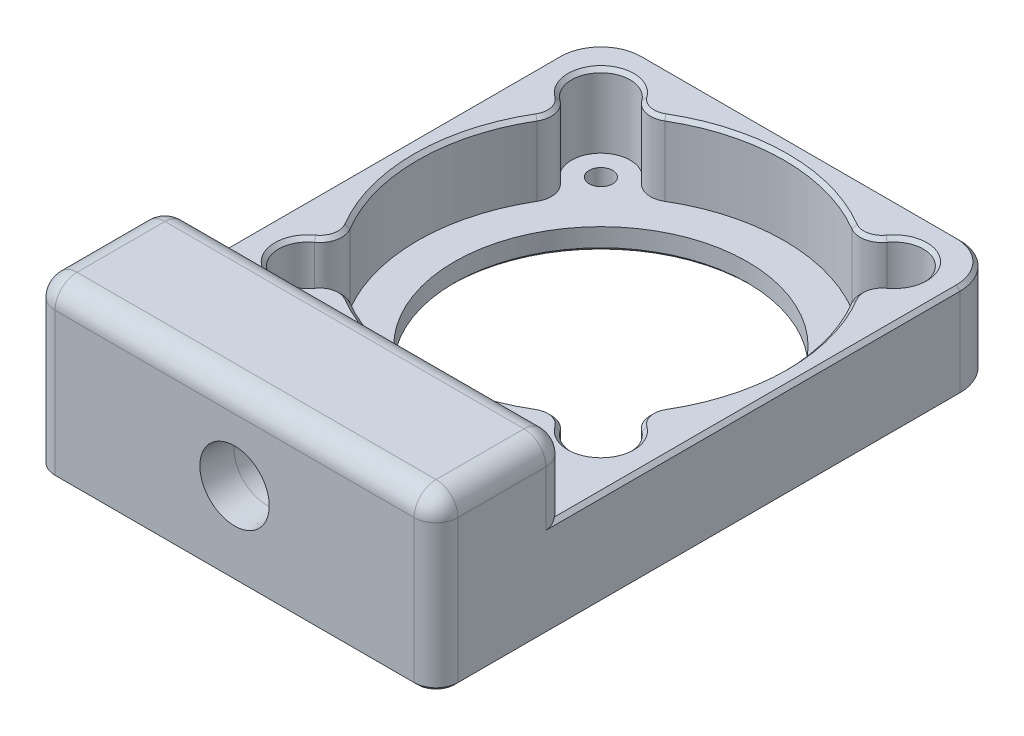
from build123d import *

# Parameters (mm, degrees)
SKETCH3_W                = 55
SKETCH3_H                = 77.5
SKETCH3_R                = 20
SKETCH3_R_2              = 1.6
BOSS_EXTRUDE1_DEPTH      = 3
SKETCH4_W                = 55
SKETCH4_H                = 77.5
SKETCH4_R                = 25
BOSS_EXTRUDE2_DEPTH      = 10
SKETCH5_R                = 4
CUT_EXTRUDE1_DEPTH       = 11
FILLET1_R                = 3
FILLET2_R                = 6
SKETCH6_W                = 55
SKETCH6_H                = 18
BOSS_EXTRUDE3_DEPTH      = 10
SKETCH7_R                = 4.4323
TRIPODMOUNT_DEPTH        = 12
FILLET3_R                = 3
CHAMFER1_SIZE            = 0.5
CHAMFER3_SIZE            = 0.5
CHAMFERTRIPODMOUNT_SIZE  = 0.3048
CHAMFERTRIPODMOUNT_SIZE2 = 4.358843075


with BuildPart() as part:
    # Sketch3 → Boss-Extrude1 (new body)
    with BuildSketch(Plane(origin=(0, 0, 0), x_dir=(1, 0, 0), z_dir=(0, 1, 0))):
        with Locations((0, -11.25)):
            Rectangle(SKETCH3_W, SKETCH3_H)
        with Locations(Location((0, 0, 0), (0, 0, 270))):  # turned: the seam where the file's is
            Circle(SKETCH3_R, mode=Mode.SUBTRACT)
        with Locations(Location((-20, 20, 0), (0, 0, 270))):  # turned: the seam where the file's is
            Circle(SKETCH3_R_2, mode=Mode.SUBTRACT)
        with Locations(Location((20, 20, 0), (0, 0, 270))):  # turned: the seam where the file's is
            Circle(SKETCH3_R_2, mode=Mode.SUBTRACT)
        with Locations(Location((20, -20, 0), (0, 0, 270))):  # turned: the seam where the file's is
            Circle(SKETCH3_R_2, mode=Mode.SUBTRACT)
        with Locations(Location((-20, -20, 0), (0, 0, 270))):  # turned: the seam where the file's is
            Circle(SKETCH3_R_2, mode=Mode.SUBTRACT)
    extrude(amount=BOSS_EXTRUDE1_DEPTH)

    # Sketch4 → Boss-Extrude2 (add)
    with BuildSketch(Plane(origin=(0, 3, 0), x_dir=(1, 0, 0), z_dir=(0, 1, 0))):
        with Locations((0, -11.25)):
            Rectangle(SKETCH4_W, SKETCH4_H)
        with Locations(Location((0, 0, 0), (0, 0, 270))):  # turned: the seam where the file's is
            Circle(SKETCH4_R, mode=Mode.SUBTRACT)
    extrude(amount=BOSS_EXTRUDE2_DEPTH)

    # Sketch5 → Cut-Extrude1 (cut, through all)
    with BuildSketch(Plane.XZ.offset(-3)):
        with Locations((20, -20)):
            Circle(SKETCH5_R)
        with Locations((-20, -20)):
            Circle(SKETCH5_R)
        with Locations((-20, 20)):
            Circle(SKETCH5_R)
        with Locations((20, 20)):
            Circle(SKETCH5_R)
    extrude(amount=-CUT_EXTRUDE1_DEPTH, mode=Mode.SUBTRACT)

    # Fillet1
    fillet1_edges = [part.edges().sort_by_distance(p)[0] for p in [
        (16.095976426, 8, 19.129023574),
        (19.129023574, 8, 16.095976426),
        (-19.129023574, 8, 16.095976426),
        (-16.095976426, 8, 19.129023574),
        (-16.095976426, 8, -19.129023574),
        (-19.129023574, 8, -16.095976426),
        (19.129023574, 8, -16.095976426),
        (16.095976426, 8, -19.129023574),
    ]]
    fillet(fillet1_edges, radius=FILLET1_R)

    # Fillet2
    fillet2_edges = [part.edges().sort_by_distance(p)[0] for p in [
        (-27.5, 6.5, -27.5),
        (27.5, 6.5, -27.5),
    ]]
    fillet(fillet2_edges, radius=FILLET2_R)

    # Sketch6 → Boss-Extrude3 (add)
    with BuildSketch(Plane(origin=(0, 13, 0), x_dir=(1, 0, 0), z_dir=(0, 1, 0))):
        with Locations((0, -41)):
            Rectangle(SKETCH6_W, SKETCH6_H)
    extrude(amount=BOSS_EXTRUDE3_DEPTH)

    # Sketch7 → TripodMount (cut)
    with BuildSketch(Plane.XY.offset(50)):
        with Locations((0, 11.5)):
            Circle(SKETCH7_R)
    extrude(amount=-TRIPODMOUNT_DEPTH, mode=Mode.SUBTRACT)

    # Fillet3
    fillet3_edges = [part.edges().sort_by_distance(p)[0] for p in [
        (-27.5, 18, 32),
        (27.5, 18, 32),
        (-27.5, 23, 41),
        (0, 23, 50),
        (27.5, 23, 41),
        (0, 23, 32),
        (27.5, 11.5, 50),
        (-27.5, 11.5, 50),
    ]]
    fillet(fillet3_edges, radius=FILLET3_R)

    # Chamfer1
    chamfer1_edges = [part.edges().sort_by_distance(p)[0] for p in [
        (0, 0, -20),
        (0, 0, -27.5),
        (-27.5, 0, 12.75),
        (-25.742640687, 0, -25.742640687),
        (25.742640687, 0, -25.742640687),
        (20, 0, -21.6),
        (27.5, 0, 12.75),
        (0, 0, 50),
        (-26.621320344, 0, 49.121320344),
        (26.621320344, 0, 49.121320344),
        (20, 0, 18.4),
        (-20, 0, 18.4),
        (-20, 0, -21.6),
    ]]
    chamfer(chamfer1_edges, length=CHAMFER1_SIZE)

    # Chamfer3
    chamfer3_edges = [part.edges().sort_by_distance(p)[0] for p in [
        (22.828427125, 13, 22.828427125),
        (0, 13, 25),
        (-22.828427125, 13, 22.828427125),
        (-25, 13, 0),
        (-22.828427125, 13, -22.828427125),
        (0, 13, -25),
        (25, 13, 0),
        (-14.921579234, 13, -21.134173852),
        (-21.134173852, 13, -14.921579234),
        (-21.134173852, 13, 14.921579234),
        (14.921579234, 13, -21.134173852),
        (21.134173852, 13, 14.921579234),
        (14.921579234, 13, 21.134173852),
        (-14.921579234, 13, 21.134173852),
        (21.134173852, 13, -14.921579234),
        (0, 13, -27.5),
        (-27.5, 13, 5.25),
        (-25.742640687, 13, -25.742640687),
        (25.742640687, 13, -25.742640687),
        (27.5, 13, 5.25),
        (22.828427125, 13, -22.828427125),
    ]]
    chamfer(chamfer3_edges, length=CHAMFER3_SIZE)

    # ChamferTripodMount
    chamfertripodmount_edges = [part.edges().sort_by_distance(p)[0] for p in [
        (-4.4323, 11.5, 50),
    ]]
    chamfertripodmount_side = [part.faces().sort_by_distance(p)[0] for p in [
        (23.972624422, 10.25, 50),
    ]]
    chamfer(chamfertripodmount_edges, length=CHAMFERTRIPODMOUNT_SIZE, length2=CHAMFERTRIPODMOUNT_SIZE2, reference=chamfertripodmount_side[0])


solid = part.part
